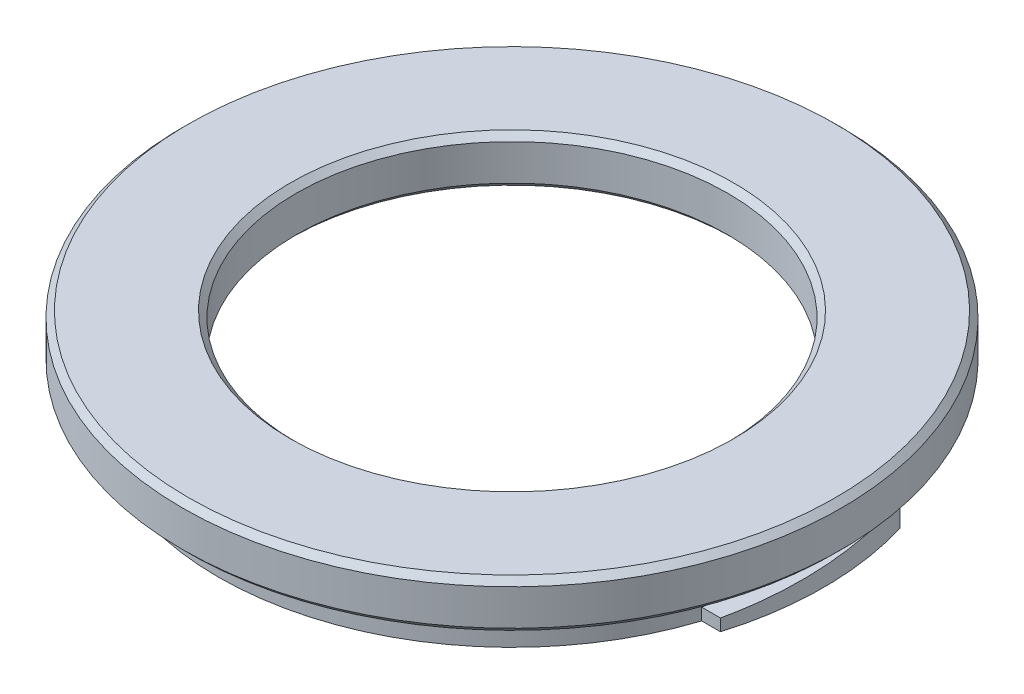
from build123d import *

# Parameters (mm, degrees)
SKIZZE1_W                       = 9.5
SKIZZE1_H                       = 4
SKIZZE1_W_2                     = 2
SKIZZE1_H_2                     = 3
AUFSATZ_LINEAR_AUSTRAGEN4_DEPTH = 30
KREISMUSTER3_COUNT              = 2
SKIZZE3_W                       = 14
SKIZZE3_H                       = 3
SKIZZE3_W_2                     = 22.5
FASE1_SIZE                      = 1
FASE2_SIZE                      = 0.5


with BuildPart() as part:
    # Skizze1 → Rotation1 (revolve)
    with BuildSketch(Plane.XY, mode=Mode.PRIVATE) as rotation1_sk:
        with Locations((-22.75, -2)):
            Rectangle(SKIZZE1_W, SKIZZE1_H)
        with Locations((-23.5, -5.5)):
            Rectangle(SKIZZE1_W_2, SKIZZE1_H_2)
    revolve(rotation1_sk.sketch.rotate(Axis((0, -13.508693245, 0), (0, 1, 0)), 270), axis=Axis((0, -13.508693245, 0), (0, 1, 0)))

    # Skizze2 → Aufsatz-Linear austragen4 (add)
    with BuildSketch(Plane(origin=(0, 0, 0), x_dir=(0, 0, -1), z_dir=(1, 0, 0))):
        Polygon((-7.5, -7), (-7.5, -6), (7.5, -5), (7.5, -7), align=None)
    aufsatz_linear_austragen4 = extrude(amount=AUFSATZ_LINEAR_AUSTRAGEN4_DEPTH)

    # Kreismuster3: Aufsatz-Linear austragen4 ×2 about axis
    kreismuster3_axis = Axis((0, 0, 0), (0, 1, 0))
    for i in range(1, KREISMUSTER3_COUNT):
        add(aufsatz_linear_austragen4.rotate(kreismuster3_axis, i * 360 / KREISMUSTER3_COUNT))

    # Skizze3 → Schnitt-Rotation1 (revolve, cut)
    with BuildSketch(Plane.XY, mode=Mode.PRIVATE) as schnitt_rotation1_sk:
        with Locations((-33, -5.5)):
            Rectangle(SKIZZE3_W, SKIZZE3_H)
        with Locations((-11.25, -5.5)):
            Rectangle(SKIZZE3_W_2, SKIZZE3_H)
    revolve(schnitt_rotation1_sk.sketch.rotate(Axis((0, 1.410628136, 0), (0, -1, 0)), 90), axis=Axis((0, 1.410628136, 0), (0, -1, 0)), mode=Mode.SUBTRACT)

    # Fase1
    fase1_edges = [part.edges().sort_by_distance(p)[0] for p in [
        (0, -4, 22.5),
    ]]
    chamfer(fase1_edges, length=FASE1_SIZE)

    # Fase2
    fase2_edges = [part.edges().sort_by_distance(p)[0] for p in [
        (0, 0, 27.5),
        (0, -7, 22.5),
        (0, 0, 18),
        (0, -4, 18),
        (0, -4, 27.5),
    ]]
    chamfer(fase2_edges, length=FASE2_SIZE)


solid = part.part
